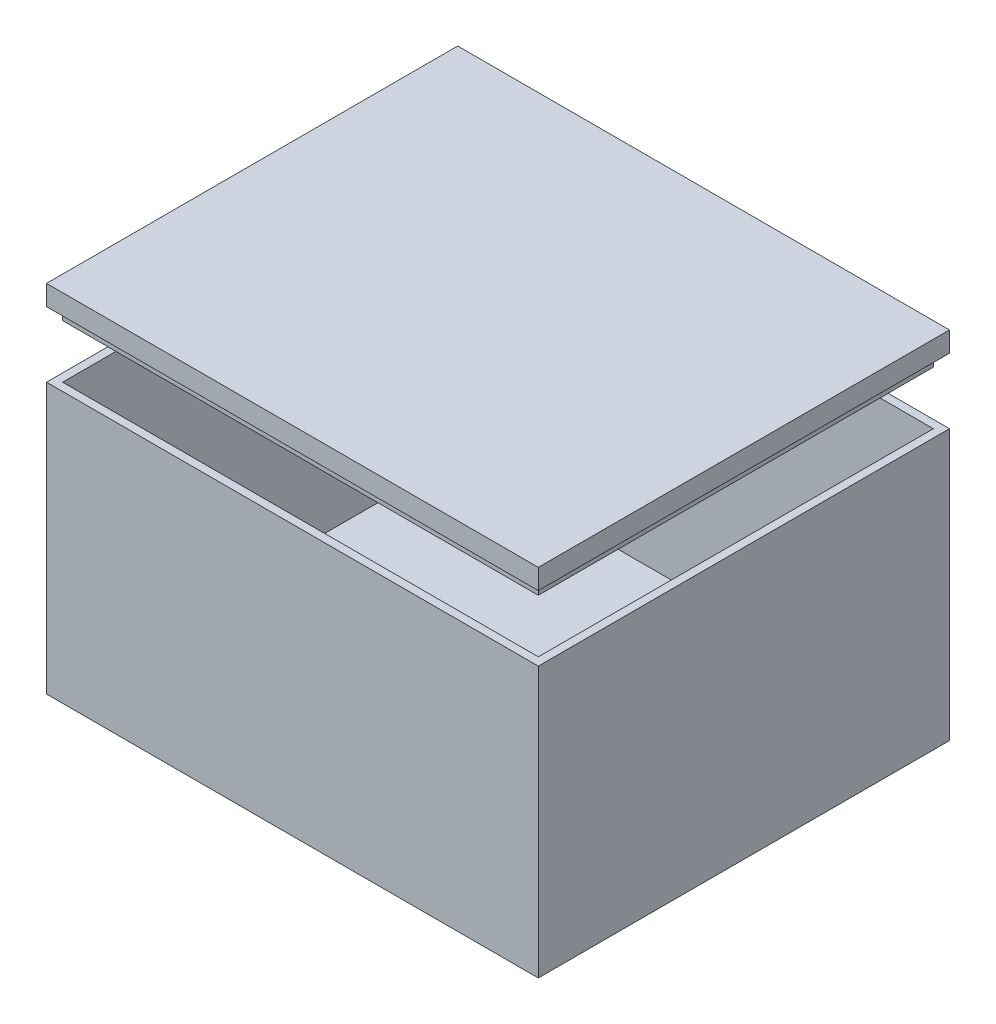
from build123d import *

# Parameters (mm, degrees)
SKETCH2_W           = 122
SKETCH2_H           = 102
BOSS_EXTRUDE1_DEPTH = 67
SHELL2_T            = -2
SKETCH7_W           = 122
SKETCH7_H           = 102
BOSS_EXTRUDE3_DEPTH = 5
SKETCH8_W           = 118
SKETCH8_H           = 98
SKETCH8_W_2         = 114
SKETCH8_H_2         = 94
EXTRUDE_THIN1_DEPTH = 3


with BuildPart() as part:
    # Sketch2 → Boss-Extrude1 (new body)
    with BuildSketch(Plane(origin=(0, 0, 0), x_dir=(1, 0, 0), z_dir=(0, 1, 0))):
        with Locations((6.476673428, -22.886409736)):
            Rectangle(SKETCH2_W, SKETCH2_H)
    extrude(amount=BOSS_EXTRUDE1_DEPTH)

    # Shell2
    shell2_openings = [part.faces().sort_by_distance(p)[0] for p in [
        (6.476673428, 67, 22.886409736),
    ]]
    offset(amount=SHELL2_T, openings=shell2_openings, kind=Kind.INTERSECTION)


with BuildPart() as body_2:
    # Sketch7 → Boss-Extrude3 (new body)
    with BuildSketch(Plane(origin=(0, 67, 0), x_dir=(1, 0, 0), z_dir=(0, 1, 0))):
        with Locations((6.476673428, -22.886409736)):
            Rectangle(SKETCH7_W, SKETCH7_H)
    extrude(amount=BOSS_EXTRUDE3_DEPTH)

    # Sketch8 → Extrude-Thin1 (add)
    with BuildSketch(Plane.XZ.offset(-67)):
        with Locations((6.476673428, 22.886409736)):
            Rectangle(SKETCH8_W, SKETCH8_H)
        with Locations((6.476673428, 22.886409736)):
            Rectangle(SKETCH8_W_2, SKETCH8_H_2, mode=Mode.SUBTRACT)
    extrude(amount=EXTRUDE_THIN1_DEPTH)


with BuildPart() as body_2_1:
    # Body-Move/Copy1: moved
    add(body_2.part.moved(Location((0, 16.223281248, 0))))


solid = Compound([part.part, body_2_1.part])
